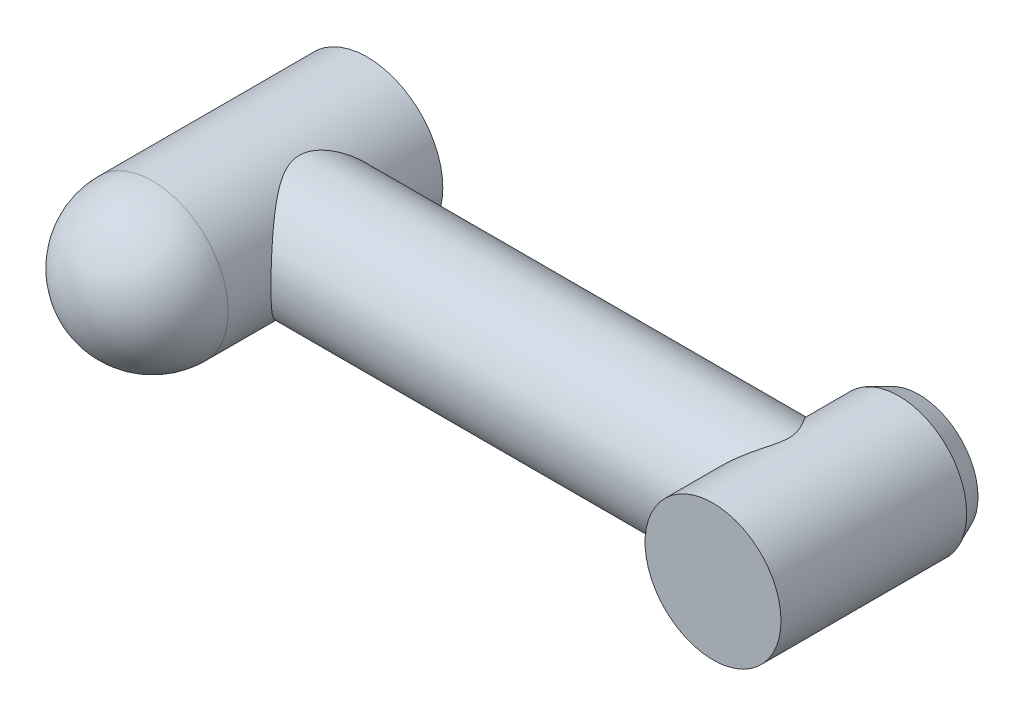
from build123d import *

# Parameters (mm, degrees)
SKETCH1_R                = 60
BOSS_EXTRUDE1_DEPTH      = 230.5
FILLET1_R                = 60
SKETCH2_R                = 51
BOSS_EXTRUDE2_DEPTH      = 438.15
BOSS_EXTRUDE3_DEPTH      = 78
BOSS_EXTRUDE3_DEPTH_BACK = 85.5
SKETCH3_R                = 53.975
CHAMFER1_SIZE            = 7
CHAMFER1_SIZE2           = 16


with BuildPart() as part:
    # Sketch1 → Boss-Extrude1 (new body)
    with BuildSketch(Plane.XY):
        Circle(SKETCH1_R)
    extrude(amount=BOSS_EXTRUDE1_DEPTH)

    # Fillet1
    fillet1_edges = [part.edges().sort_by_distance(p)[0] for p in [
        (-60, 0, 230.5),
    ]]
    fillet(fillet1_edges, radius=FILLET1_R)

    # Sketch2 → Boss-Extrude2 (add)
    with BuildSketch(Plane(origin=(0, 0, 0), x_dir=(0, 0, -1), z_dir=(1, 0, 0))):
        with Locations((-85.5, 0)):
            Circle(SKETCH2_R)
    extrude(amount=BOSS_EXTRUDE2_DEPTH)

    # Sketch3 → Boss-Extrude3 (add, two sides: drawn at the far end of the back side and taken through both)
    with BuildSketch(Plane.XY.offset(85.5).offset(-BOSS_EXTRUDE3_DEPTH_BACK)):
        with Locations((438.15, 0)):
            Circle(SKETCH3_R)
    extrude(amount=BOSS_EXTRUDE3_DEPTH + BOSS_EXTRUDE3_DEPTH_BACK)

    # Chamfer1
    chamfer1_edges = [part.edges().sort_by_distance(p)[0] for p in [
        (384.175, 0, 0),
    ]]
    chamfer1_side = [part.faces().sort_by_distance(p)[0] for p in [
        (438.15, 0, 0),
    ]]
    chamfer(chamfer1_edges, length=CHAMFER1_SIZE, length2=CHAMFER1_SIZE2, reference=chamfer1_side[0])


solid = part.part
